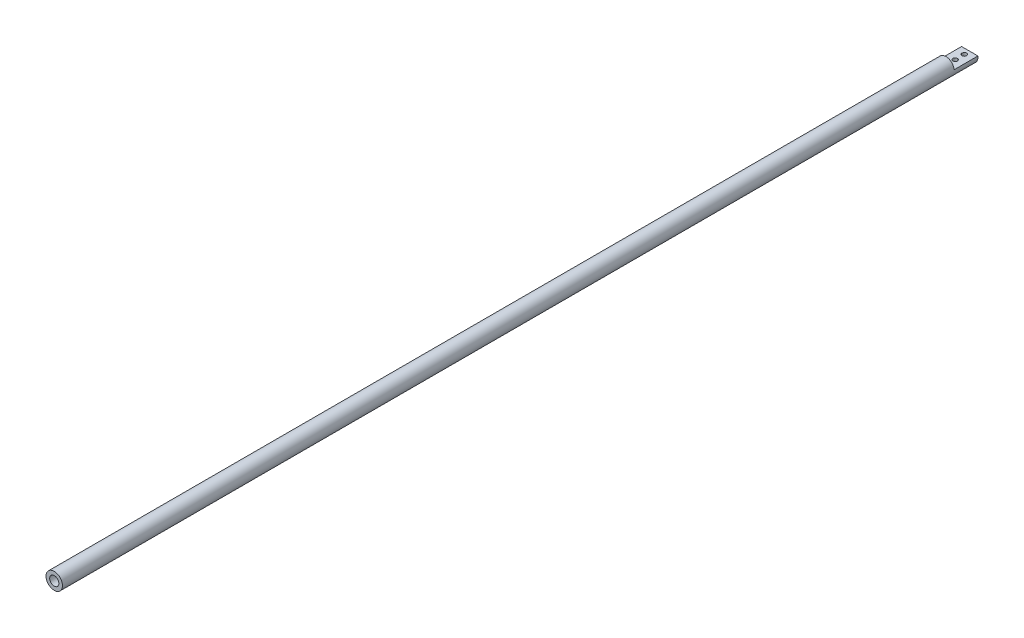
from build123d import *

# Parameters (mm, degrees)
CROQUIS1_R              = 9
SALIENTE_EXTRUIR1_DEPTH = 1000
CROQUIS2_R              = 5
CORTAR_EXTRUIR1_DEPTH   = 30
CORTAR_EXTRUIR2_DEPTH   = 26
CROQUIS5_R              = 2.5
CORTAR_EXTRUIR3_DEPTH   = 10


with BuildPart() as part:
    # Croquis1 → Saliente-Extruir1 (new body)
    with BuildSketch(Plane.XY):
        Circle(CROQUIS1_R)
    extrude(amount=SALIENTE_EXTRUIR1_DEPTH)

    # Croquis2 → Cortar-Extruir1 (cut)
    with BuildSketch(Plane.XY.offset(1000)):
        Circle(CROQUIS2_R)
    extrude(amount=-CORTAR_EXTRUIR1_DEPTH, mode=Mode.SUBTRACT)

    # Croquis4 → Cortar-Extruir2 (cut)
    with BuildSketch(Plane(origin=(0, 0, 0), x_dir=(-1, 0, 0), z_dir=(0, 0, -1))):
        with BuildLine():
            Line((-8.94427191, 1), (8.94427191, 1))
            ThreePointArc((8.94427191, 1), (6, 6.708203932), (0, 9))
            ThreePointArc((0, 9), (-6, 6.708203932), (-8.94427191, 1))
        make_face()
    extrude(amount=-CORTAR_EXTRUIR2_DEPTH, mode=Mode.SUBTRACT)

    # Croquis5 → Cortar-Extruir3 (cut)
    with BuildSketch(Plane(origin=(0, 1, 0), x_dir=(1, 0, 0), z_dir=(0, 1, 0))):
        with Locations((0, -6)):
            Circle(CROQUIS5_R)
        with Locations((0, -16)):
            Circle(CROQUIS5_R)
    extrude(amount=-CORTAR_EXTRUIR3_DEPTH, mode=Mode.SUBTRACT)


solid = part.part
